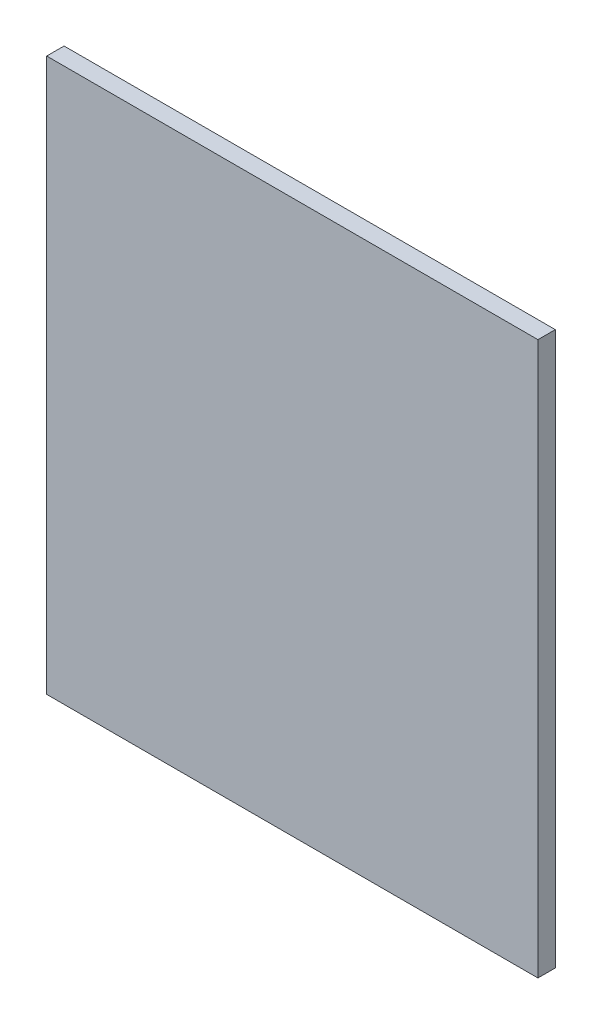
from build123d import *

# Parameters (mm, degrees)
SKETCH1_W           = 78.994
SKETCH1_H           = 2.794
BOSS_EXTRUDE1_DEPTH = 88.9


with BuildPart() as part:
    # Sketch1 → Boss-Extrude1 (new body)
    with BuildSketch(Plane(origin=(0, 0, 0), x_dir=(1, 0, 0), z_dir=(0, 1, 0))):
        with Locations((39.497, 1.397)):
            Rectangle(SKETCH1_W, SKETCH1_H)
    extrude(amount=BOSS_EXTRUDE1_DEPTH)


solid = part.part
